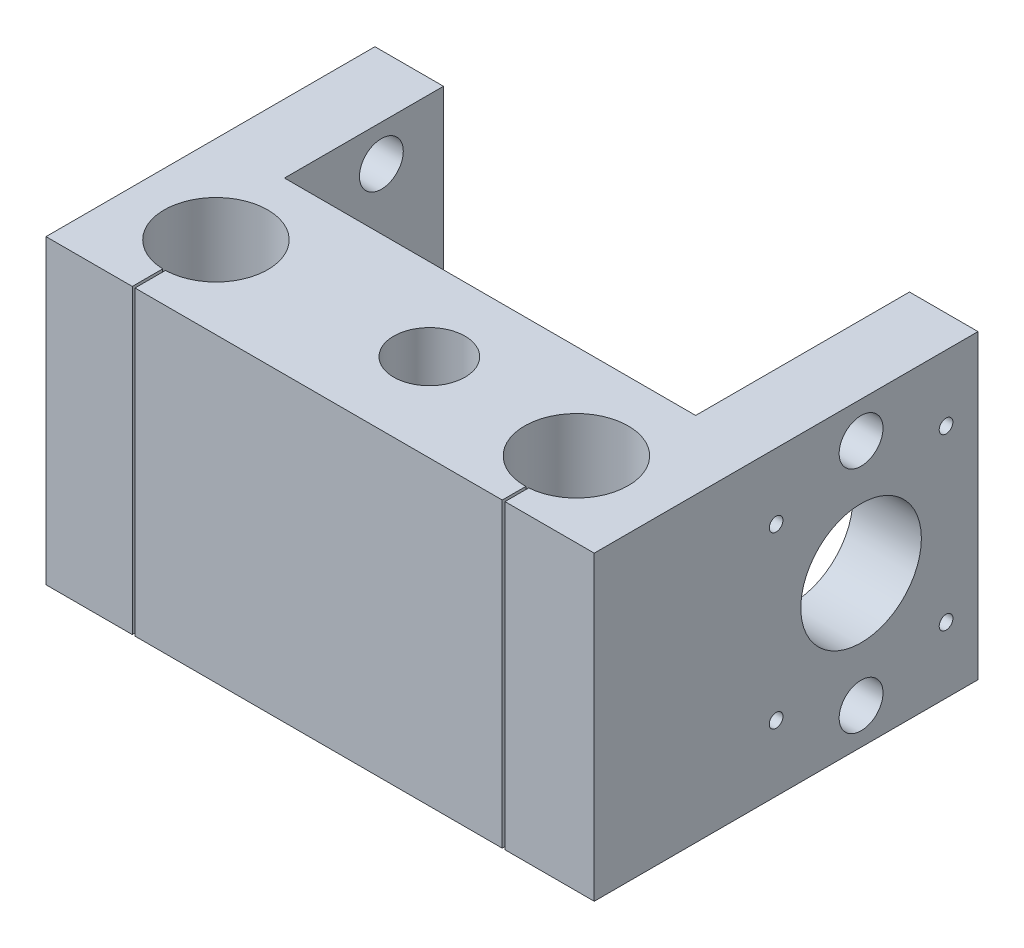
from build123d import *

# Parameters (mm, degrees)
BOSS_EXTRUDE1_DEPTH     = 55
SKETCH2_W               = 12.5
SKETCH2_H               = 55
CUT_EXTRUDE1_DEPTH      = 10
SKETCH4_R               = 9.45
CUT_EXTRUDE2_DEPTH      = 56
SKETCH5_R               = 9.45
CUT_EXTRUDE3_DEPTH      = 56
SKETCH7_R               = 1.25
CUT_EXTRUDE5_DEPTH      = 35
SKETCH8_R               = 11
CUT_EXTRUDE6_DEPTH      = 35
SKETCH9_R               = 4
CUT_EXTRUDE7_DEPTH      = 1
CUT_EXTRUDE7_DEPTH_BACK = 101
SKETCH11_R              = 4
CUT_EXTRUDE8_DEPTH      = 100
SKETCH12_W              = 0.5
SKETCH12_H              = 7.437726557
SKETCH12_H_2            = 9.137996941
CUT_EXTRUDE9_DEPTH      = 56
SKETCH13_R              = 6.5
CUT_EXTRUDE10_DEPTH     = 56


with BuildPart() as part:
    # Sketch1 → Boss-Extrude1 (new body)
    with BuildSketch(Plane(origin=(0, 0, 0), x_dir=(1, 0, 0), z_dir=(0, 1, 0))):
        Polygon((-37.5, 35), (-50, 35), (-50, -35), (50, -35), (50, 35), (37.5, 35), (37.5, -4), (-37.5, -4), align=None)
    extrude(amount=BOSS_EXTRUDE1_DEPTH)

    # Sketch2 → Cut-Extrude1 (cut)
    with BuildSketch(Plane(origin=(0, 0, -35), x_dir=(-1, 0, 0), z_dir=(0, 0, -1))):
        with Locations((43.75, 27.5)):
            Rectangle(SKETCH2_W, SKETCH2_H)
    extrude(amount=-CUT_EXTRUDE1_DEPTH, mode=Mode.SUBTRACT)

    # Sketch4 → Cut-Extrude2 (cut, through all)
    with BuildSketch(Plane(origin=(0, 55, 0), x_dir=(1, 0, 0), z_dir=(0, 1, 0))):
        with Locations((33, -21.25)):
            Circle(SKETCH4_R)
    extrude(amount=-CUT_EXTRUDE2_DEPTH, mode=Mode.SUBTRACT)

    # Sketch5 → Cut-Extrude3 (cut, through all)
    with BuildSketch(Plane(origin=(0, 55, 0), x_dir=(1, 0, 0), z_dir=(0, 1, 0))):
        with Locations((-34, -20)):
            Circle(SKETCH5_R)
    extrude(amount=-CUT_EXTRUDE3_DEPTH, mode=Mode.SUBTRACT)

    # Sketch7 → Cut-Extrude5 (cut)
    with BuildSketch(Plane(origin=(50, 0, 0), x_dir=(0, 0, -1), z_dir=(1, 0, 0))):
        with Locations((29.173129307, 12)):
            Circle(SKETCH7_R)
        with Locations((-1.826870693, 12)):
            Circle(SKETCH7_R)
        with Locations((-1.826870693, 43)):
            Circle(SKETCH7_R)
        with Locations((29.173129307, 43)):
            Circle(SKETCH7_R)
    extrude(amount=-CUT_EXTRUDE5_DEPTH, mode=Mode.SUBTRACT)

    # Sketch8 → Cut-Extrude6 (cut)
    with BuildSketch(Plane(origin=(50, 0, 0), x_dir=(0, 0, -1), z_dir=(1, 0, 0))):
        with Locations((13.673129307, 27.5)):
            Circle(SKETCH8_R)
    extrude(amount=-CUT_EXTRUDE6_DEPTH, mode=Mode.SUBTRACT)

    # Sketch9 → Cut-Extrude7 (cut, two sides)
    with BuildSketch(Plane(origin=(50, 0, 0), x_dir=(0, 0, -1), z_dir=(1, 0, 0))) as cut_extrude7_sk:
        with Locations((13.673129307, 48.4)):
            Circle(SKETCH9_R)
        with Locations((13.673129307, 6.6)):
            Circle(SKETCH9_R)
    extrude(amount=CUT_EXTRUDE7_DEPTH, mode=Mode.SUBTRACT)
    extrude(cut_extrude7_sk.sketch, amount=-CUT_EXTRUDE7_DEPTH_BACK, mode=Mode.SUBTRACT)

    # Sketch11 → Cut-Extrude8 (cut)
    with BuildSketch(Plane(origin=(-37.5, 0, 0), x_dir=(0, 0, -1), z_dir=(1, 0, 0))):
        with Locations((13.673129307, 27.5)):
            Circle(SKETCH11_R)
    extrude(amount=-CUT_EXTRUDE8_DEPTH, mode=Mode.SUBTRACT)

    # Sketch12 → Cut-Extrude9 (cut, through all)
    with BuildSketch(Plane.XZ):
        with Locations((33.471458783, 32.290249866)):
            Rectangle(SKETCH12_W, SKETCH12_H)
        with Locations((-34.014056432, 31.597087229)):
            Rectangle(SKETCH12_W, SKETCH12_H_2)
    extrude(amount=-CUT_EXTRUDE9_DEPTH, mode=Mode.SUBTRACT)

    # Sketch13 → Cut-Extrude10 (cut, through all)
    with BuildSketch(Plane(origin=(0, 55, 0), x_dir=(1, 0, 0), z_dir=(0, 1, 0))):
        with Locations((3.925383248, -19)):
            Circle(SKETCH13_R)
    extrude(amount=-CUT_EXTRUDE10_DEPTH, mode=Mode.SUBTRACT)


solid = part.part
